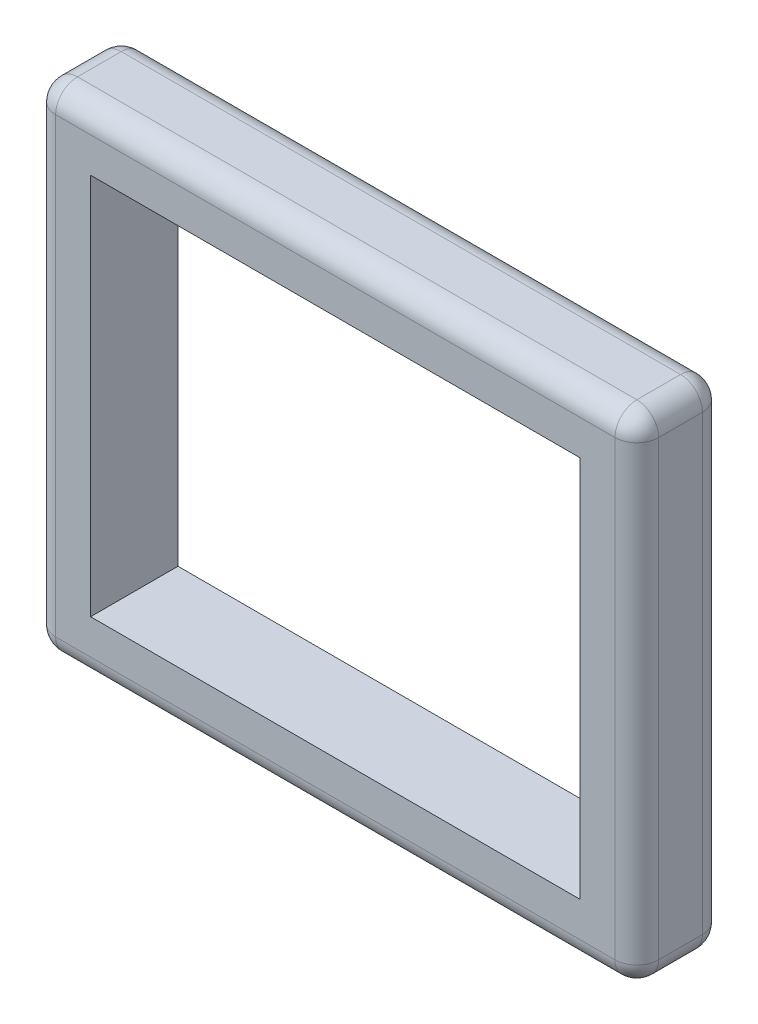
from build123d import *

# Parameters (mm, degrees)
SKETCH1_W           = 876.3
SKETCH1_H           = 720.725
SKETCH1_W_2         = 711.2
SKETCH1_H_2         = 555.625
BOSS_EXTRUDE1_DEPTH = 127
FILLET1_R           = 31.75


with BuildPart() as part:
    # Sketch1 → Boss-Extrude1 (new body)
    with BuildSketch(Plane.XY):
        with Locations((355.6, 277.8125)):
            Rectangle(SKETCH1_W, SKETCH1_H)
        with Locations((355.6, 277.8125)):
            Rectangle(SKETCH1_W_2, SKETCH1_H_2, mode=Mode.SUBTRACT)
    extrude(amount=BOSS_EXTRUDE1_DEPTH)

    # Fillet1
    fillet1_edges = [part.edges().sort_by_distance(p)[0] for p in [
        (355.6, 638.175, 127),
        (355.6, -82.55, 0),
        (-82.55, 277.8125, 0),
        (355.6, 638.175, 0),
        (793.75, 277.8125, 0),
        (-82.55, 277.8125, 127),
        (793.75, -82.55, 63.5),
        (-82.55, -82.55, 63.5),
        (-82.55, 638.175, 63.5),
        (793.75, 638.175, 63.5),
        (355.6, -82.55, 127),
        (793.75, 277.8125, 127),
    ]]
    fillet(fillet1_edges, radius=FILLET1_R)


solid = part.part
